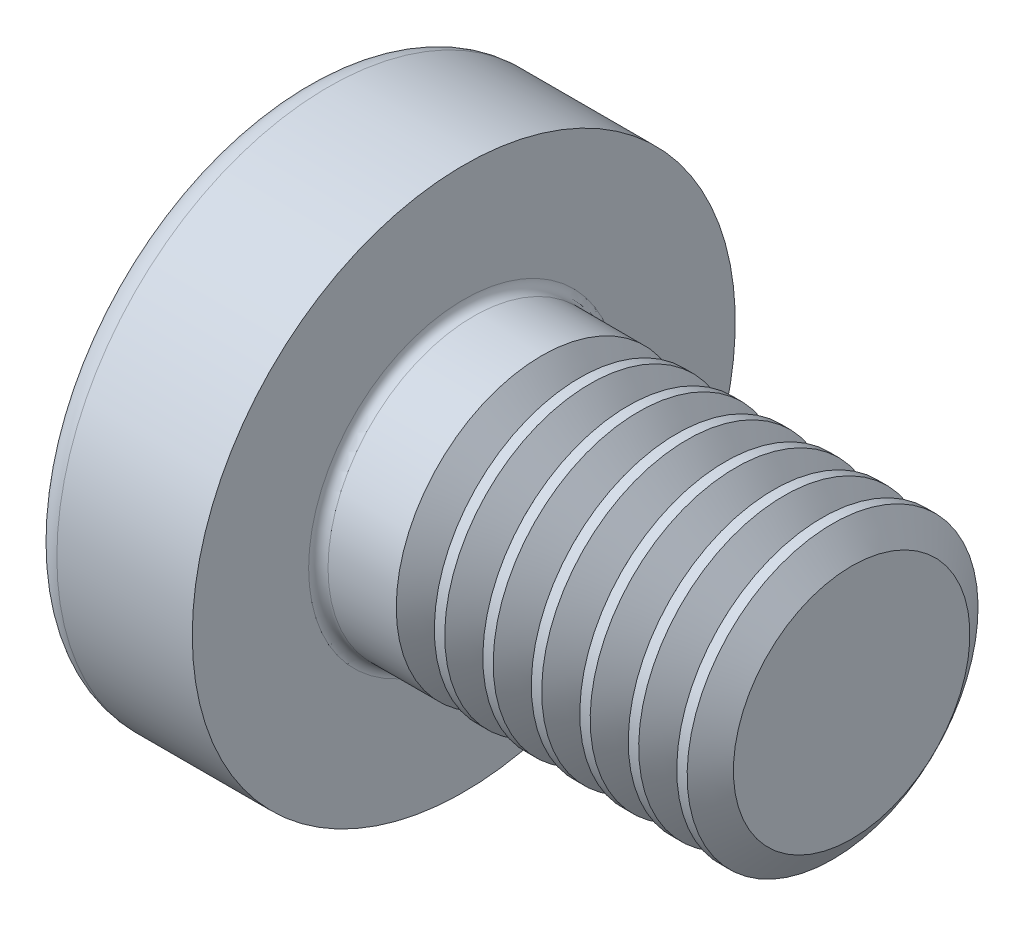
from build123d import *

# Parameters (mm, degrees)
FILLET1_R       = 0.1
SKETCH3_W       = 0.74
SKETCH3_H       = 2.8
SKETCH4_W       = 0.74
SKETCH4_H       = 1.054964664
RECPAT_COUNT    = 2
RECPAT_ANGLE    = 90
THDSCHPAT_COUNT = 7
THDSCHPAT_PITCH = 0.5


with BuildPart() as part:
    # BodySke → Base-Revolve (revolve)
    with BuildSketch(Plane.XY):
        with BuildLine():
            Line((2.4, 1.5), (2.4, 2.8))
            Line((2.4, 2.8), (1.003501533, 2.8))
            ThreePointArc((1.003501533, 2.8), (0.873295971, 2.76653015), (0.775371599, 2.674418605))
            ThreePointArc((0.775371599, 2.674418605), (0.197753546, 1.392274756), (0, 0))
            Line((0, 0), (6.4, 0))
            Line((6.4, 0), (6.4, 1.5))
            Line((6.4, 1.5), (2.4, 1.5))
        make_face()
    revolve(axis=Axis((-25.4, 0, 0), (1, 0, 0)))

    # Fillet1
    fillet1_edges = [part.edges().sort_by_distance(p)[0] for p in [
        (2.4, -1.5, 0),
    ]]
    fillet(fillet1_edges, radius=FILLET1_R)

    # Sketch3 → Recess section 0
    with BuildSketch(Plane(origin=(0, 0, 0), x_dir=(0, 0, -1), z_dir=(1, 0, 0))):
        Rectangle(SKETCH3_W, SKETCH3_H)
    # Sketch4 → Recess section 1
    with BuildSketch(Plane(origin=(1.75, 0, 0), x_dir=(0, 0, -1), z_dir=(1, 0, 0))):
        Rectangle(SKETCH4_W, SKETCH4_H)
    recess = loft(mode=Mode.SUBTRACT)

    # RecPat: Recess ×2 about axis
    recpat_axis = Axis((0, 0, 0), (1, 0, 0))
    for i in range(1, RECPAT_COUNT):
        add(recess.rotate(recpat_axis, i * RECPAT_ANGLE / (RECPAT_COUNT - 1)), mode=Mode.SUBTRACT)

    # RecCorSke → RecessCore (revolve, cut)
    with BuildSketch(Plane.XY):
        Polygon((0, 0), (0, 0.678371921), (1.75, 0.556), (1.930655351, 0), align=None)
    revolve(axis=Axis((-3.175, 0, 0), (1, 0, 0)), mode=Mode.SUBTRACT)

    # ThdSchSke → ThreadSchematic (revolve, cut)
    with BuildSketch(Plane.XY):
        Polygon((3.4, -1.2195), (3.203591786, -1.5), (3.203591786, -1.875), (3.596408214, -1.875), (3.596408214, -1.5), align=None)
    threadschematic = revolve(axis=Axis((-3.175, 0, 0), (1, 0, 0)), mode=Mode.SUBTRACT)

    # ThdSchPat: ThreadSchematic ×7
    with Locations(*[(i * THDSCHPAT_PITCH, 0, 0) for i in range(1, THDSCHPAT_COUNT)]):
        add(threadschematic, mode=Mode.SUBTRACT)


solid = part.part
